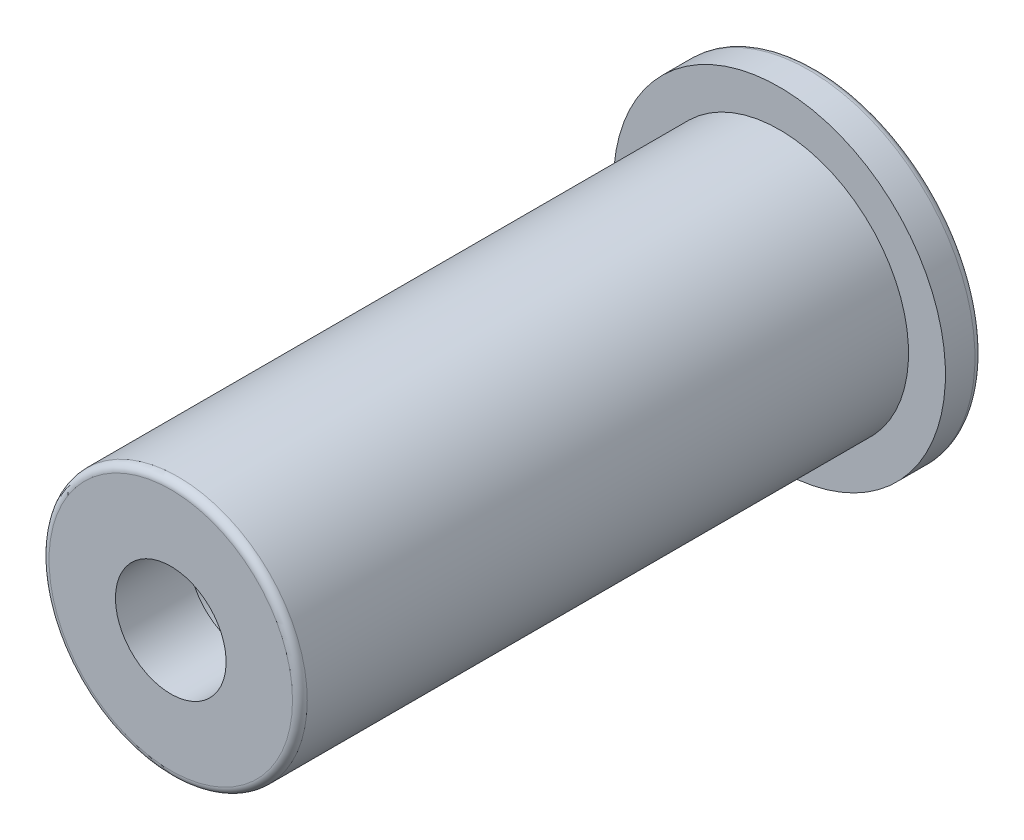
from build123d import *

# Parameters (mm, degrees)
FILLET_1_R = 0.4


with BuildPart() as part:
    # Эскиз1 → Повернуть1 (revolve)
    with BuildSketch(Plane(origin=(0, 0, 0), x_dir=(0, 0, -1), z_dir=(1, 0, 0))):
        Polygon((-2, 7), (-2, 9), (0, 9), (0, 4.5), (-31, 4.5), (-31, 3), (-35, 3), (-35, 7), align=None)
    revolve(axis=Axis((0, 0, -80.9), (0, 0, 1)))

    # Скругление1
    fillet_1_edges = [part.edges().sort_by_distance(p)[0] for p in [
        (0, -7, 35),
        (0, -9, 0),
    ]]
    fillet(fillet_1_edges, radius=FILLET_1_R)


solid = part.part
